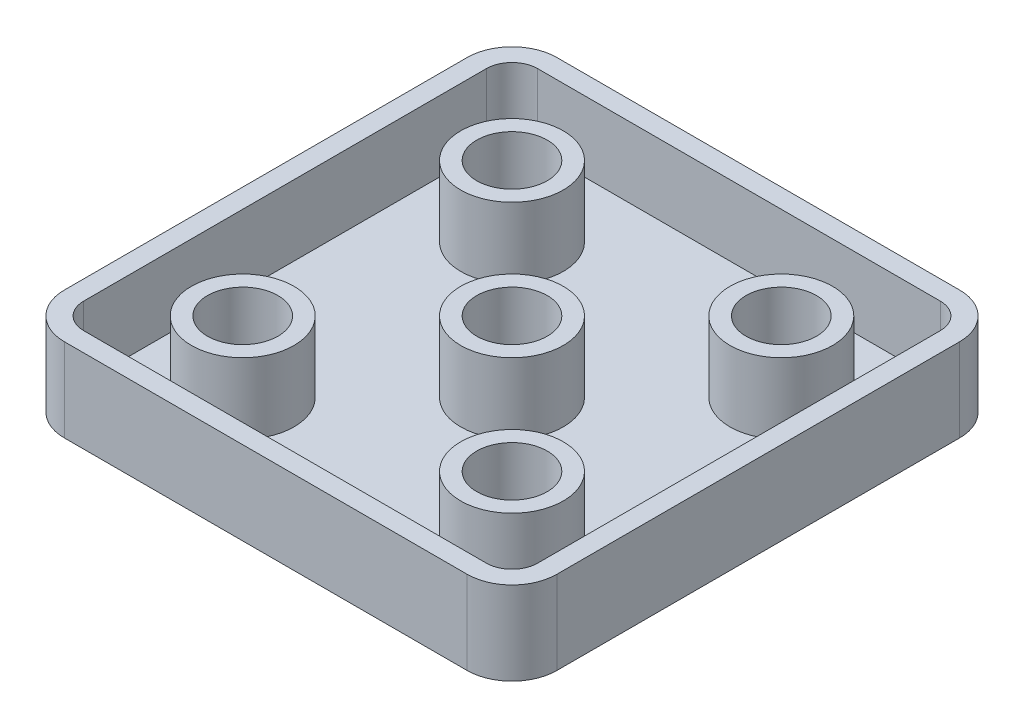
from build123d import *

# Parameters (mm, degrees)
SKETCH1_W           = 38.4
SKETCH1_H           = 38.4
BOSS_EXTRUDE1_DEPTH = 6.5
FILLET1_R           = 3.5
SKETCH7_R           = 4
SKETCH7_R_2         = 2.75
CUT_EXTRUDE1_DEPTH  = 5.5
SKETCH8_R           = 2.75
CUT_EXTRUDE2_DEPTH  = 0.4


with BuildPart() as part:
    # Sketch1 → Boss-Extrude1 (new body)
    with BuildSketch(Plane(origin=(0, 0, 0), x_dir=(1, 0, 0), z_dir=(0, 1, 0))):
        with Locations((-19.2, -19.2)):
            Rectangle(SKETCH1_W, SKETCH1_H)
    extrude(amount=BOSS_EXTRUDE1_DEPTH)

    # Fillet1
    fillet1_edges = [part.edges().sort_by_distance(p)[0] for p in [
        (0, 3.25, 38.4),
        (-38.4, 3.25, 38.4),
        (-38.4, 3.25, 0),
        (0, 3.25, 0),
    ]]
    fillet(fillet1_edges, radius=FILLET1_R)

    # Sketch7 → Cut-Extrude1 (cut)
    with BuildSketch(Plane(origin=(0, 6.5, 0), x_dir=(1, 0, 0), z_dir=(0, 1, 0))):
        with BuildLine():
            Line((-3.5, -1.5), (-34.9, -1.5))
            ThreePointArc((-34.9, -1.5), (-36.314213562, -2.085786438), (-36.9, -3.5))
            Line((-36.9, -3.5), (-36.9, -34.9))
            ThreePointArc((-36.9, -34.9), (-36.314213562, -36.314213562), (-34.9, -36.9))
            Line((-34.9, -36.9), (-3.5, -36.9))
            ThreePointArc((-3.5, -36.9), (-2.085786438, -36.314213562), (-1.5, -34.9))
            Line((-1.5, -34.9), (-1.5, -3.5))
            ThreePointArc((-1.5, -3.5), (-2.085786438, -2.085786438), (-3.5, -1.5))
        make_face()
        with Locations((-19.2, -19.2)):
            Circle(SKETCH7_R, mode=Mode.SUBTRACT)
        with Locations((-29.7, -29.7)):
            Circle(SKETCH7_R, mode=Mode.SUBTRACT)
        with Locations((-8.7, -29.7)):
            Circle(SKETCH7_R, mode=Mode.SUBTRACT)
        with Locations((-8.7, -8.7)):
            Circle(SKETCH7_R, mode=Mode.SUBTRACT)
        with Locations((-29.7, -8.7)):
            Circle(SKETCH7_R, mode=Mode.SUBTRACT)
        with Locations((-29.7, -8.7)):
            Circle(SKETCH7_R_2)
        with Locations((-8.7, -8.7)):
            Circle(SKETCH7_R_2)
        with Locations((-19.2, -19.2)):
            Circle(SKETCH7_R_2)
        with Locations((-29.7, -29.7)):
            Circle(SKETCH7_R_2)
        with Locations((-8.7, -29.7)):
            Circle(SKETCH7_R_2)
    extrude(amount=-CUT_EXTRUDE1_DEPTH, mode=Mode.SUBTRACT)

    # Sketch8 → Cut-Extrude2 (cut)
    with BuildSketch(Plane(origin=(0, 1, 0), x_dir=(1, 0, 0), z_dir=(0, 1, 0))):
        with Locations((-29.7, -29.7)):
            Circle(SKETCH8_R)
        with Locations((-8.7, -29.7)):
            Circle(SKETCH8_R)
        with Locations((-8.7, -8.7)):
            Circle(SKETCH8_R)
        with Locations((-19.2, -19.2)):
            Circle(SKETCH8_R)
        with Locations((-29.7, -8.7)):
            Circle(SKETCH8_R)
    extrude(amount=-CUT_EXTRUDE2_DEPTH, mode=Mode.SUBTRACT)


solid = part.part
